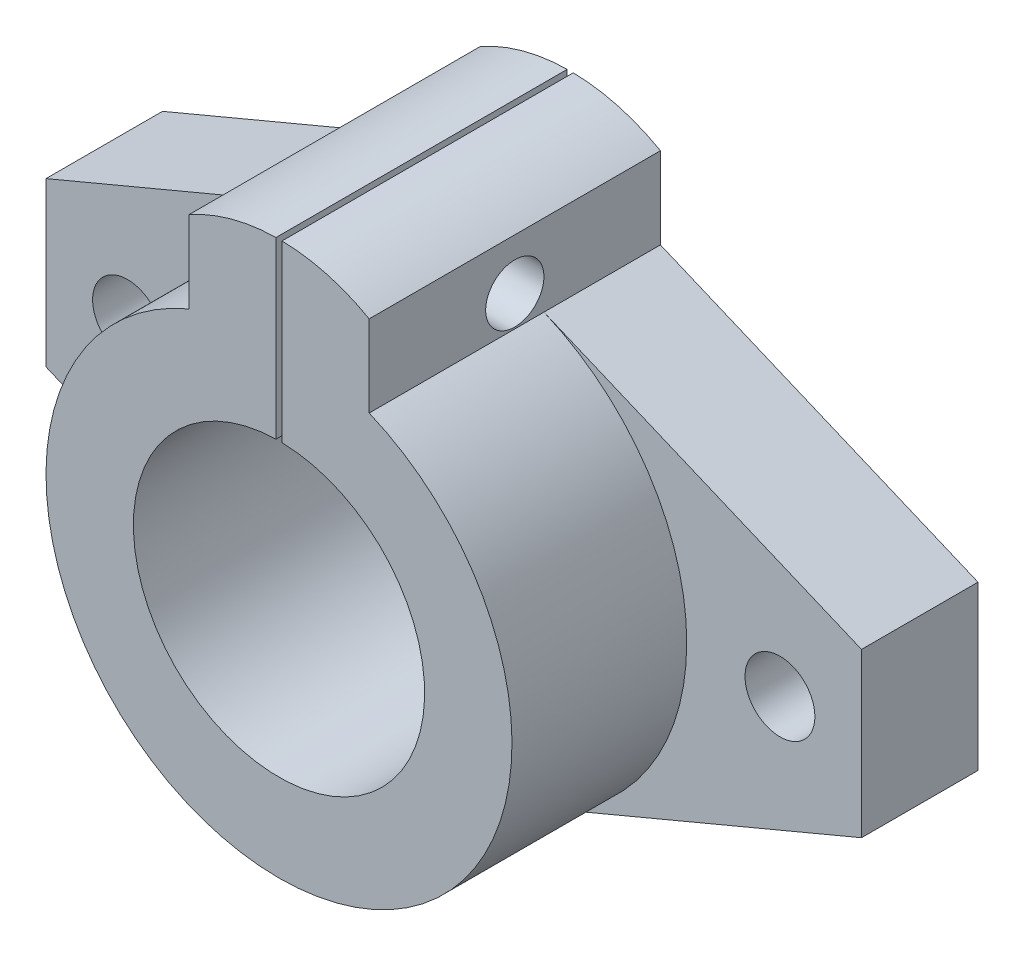
from build123d import *

# Parameters (mm, degrees)
SKETCH_1_R          = 3
SKETCH_1_R_2        = 12.5
EXTRUDE_2_DEPTH     = 10
SKETCH_2_R          = 12.5
EXTRUDE_3_DEPTH     = 15
SKETCH_3_W          = 0.517195108
SKETCH_3_H          = 18.726193104
CUT_EXTRUDE_1_DEPTH = 26
SKETCH_4_R          = 2.5
CUT_EXTRUDE_2_DEPTH = 43.740275714


with BuildPart() as part:
    # 草图1 → 凸台-拉伸2 (new body)
    with BuildSketch(Plane.XY):
        with BuildLine():
            Line((-35, -7), (-7.740275714, -18.44147857))
            ThreePointArc((-7.740275714, -18.44147857), (0, -20), (7.740275714, -18.44147857))
            Line((7.740275714, -18.44147857), (35, -7))
            Line((35, -7), (35, 7))
            Line((35, 7), (7.740275714, 18.44147857))
            Line((7.740275714, 18.44147857), (7.740275714, 25.44147857))
            ThreePointArc((7.740275714, 25.44147857), (0, 27.494244152), (-7.740275714, 25.44147857))
            Line((-7.740275714, 25.44147857), (-7.740275714, 18.44147857))
            Line((-7.740275714, 18.44147857), (-35, 7))
            Line((-35, 7), (-35, -7))
        make_face()
        with Locations((-28, 0)):
            Circle(SKETCH_1_R, mode=Mode.SUBTRACT)
        Circle(SKETCH_1_R_2, mode=Mode.SUBTRACT)
        with Locations((28, 0)):
            Circle(SKETCH_1_R, mode=Mode.SUBTRACT)
    extrude(amount=EXTRUDE_2_DEPTH)

    # 草图2 → 凸台-拉伸3 (add)
    with BuildSketch(Plane.XY.offset(10)):
        with BuildLine():
            Line((-7.740275714, 18.44147857), (-7.740275714, 25.44147857))
            ThreePointArc((-7.740275714, 25.44147857), (0, 27.494244152), (7.740275714, 25.44147857))
            Line((7.740275714, 25.44147857), (7.740275714, 18.44147857))
            ThreePointArc((7.740275714, 18.44147857), (0, -20), (-7.740275714, 18.44147857))
        make_face()
        Circle(SKETCH_2_R, mode=Mode.SUBTRACT)
    extrude(amount=EXTRUDE_3_DEPTH)

    # 草图3 → 切除-拉伸1 (cut, through all)
    with BuildSketch(Plane.XY.offset(25)):
        with Locations((0, 21.741202931)):
            Rectangle(SKETCH_3_W, SKETCH_3_H)
    extrude(amount=-CUT_EXTRUDE_1_DEPTH, mode=Mode.SUBTRACT)

    # 草图4 → 切除-拉伸2 (cut, through all)
    with BuildSketch(Plane(origin=(7.740275714, 0, 0), x_dir=(0, 0, -1), z_dir=(1, 0, 0))):
        with Locations((-12.5, 21.086423576)):
            Circle(SKETCH_4_R)
    extrude(amount=-CUT_EXTRUDE_2_DEPTH, mode=Mode.SUBTRACT)


solid = part.part
